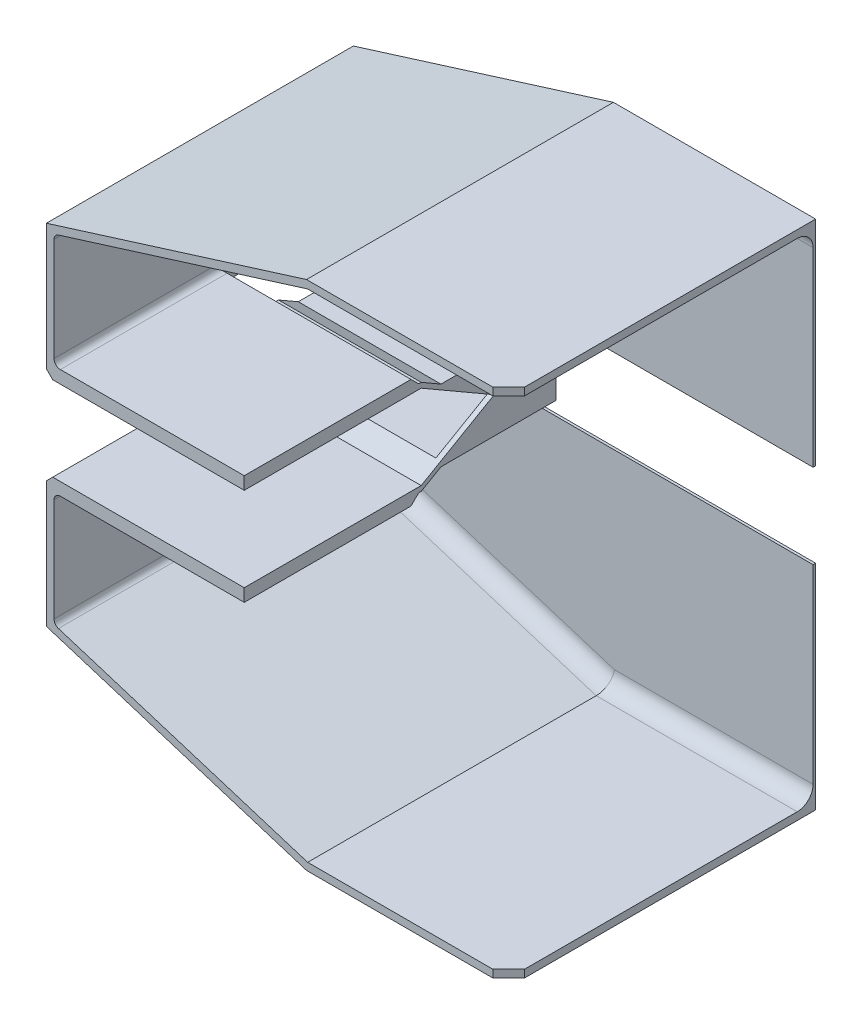
from build123d import *

# Parameters (mm, degrees)
BOSS_EXTRUDE1_DEPTH = 96
BOSS_EXTRUDE2_DEPTH = 2.4
SKETCH3_W           = 2.4
SKETCH3_H           = 61
CUT_EXTRUDE1_DEPTH  = 96
SKETCH4_W           = 143.4
SKETCH4_H           = 41
CUT_EXTRUDE2_DEPTH  = 5
SKETCH9_W           = 83.4
SKETCH9_H           = 55
CUT_EXTRUDE4_DEPTH  = 5
CUT_EXTRUDE3_DEPTH  = 60
BOSS_EXTRUDE3_DEPTH = 45
BOSS_EXTRUDE4_DEPTH = 1.6
CHAMFER1_SIZE       = 5
FILLET1_R           = 2
FILLET3_R           = 5
FILLET4_R           = 2
CHAMFER2_SIZE       = 1.6
CHAMFER3_SIZE       = 2


with BuildPart() as part:
    # Sketch1 → Boss-Extrude1 (new body)
    with BuildSketch(Plane.XY):
        Polygon((145.8, 0), (145.8, 65.8), (82.033733785, 65.8), (0, 40.164458192), (0, 0), (0, -1.6), (145.8, -1.6), align=None)
        Polygon((2.4, 38.4), (2.4, 2.4), (143.4, 2.4), (143.4, 63.4), (82.4, 63.4), align=None, mode=Mode.SUBTRACT)
    extrude(amount=BOSS_EXTRUDE1_DEPTH)

    # Sketch2 → Boss-Extrude2 (add)
    with BuildSketch(Plane(origin=(0, 0, 0), x_dir=(-1, 0, 0), z_dir=(0, 0, -1))):
        Polygon((-145.8, 0), (-145.8, 65.8), (-82.033733785, 65.8), (0, 40.164458192), (0, 0), (0, -1.6), (-145.8, -1.6), align=None)
    extrude(amount=BOSS_EXTRUDE2_DEPTH)

    # Sketch3 → Cut-Extrude1 (cut)
    with BuildSketch(Plane.XY.offset(96)):
        with Locations((144.6, 32.9)):
            Rectangle(SKETCH3_W, SKETCH3_H)
    extrude(amount=-CUT_EXTRUDE1_DEPTH, mode=Mode.SUBTRACT)

    # Sketch4 → Cut-Extrude2 (cut, through all)
    with BuildSketch(Plane(origin=(0, 2.4, 0), x_dir=(1, 0, 0), z_dir=(0, 1, 0))):
        with Locations((74.1, -20.5)):
            Rectangle(SKETCH4_W, SKETCH4_H)
    extrude(amount=-CUT_EXTRUDE2_DEPTH, mode=Mode.SUBTRACT)

    # Sketch9 → Cut-Extrude4 (cut, through all)
    with BuildSketch(Plane(origin=(0, 2.4, 0), x_dir=(1, 0, 0), z_dir=(0, 1, 0))):
        with Locations((104.1, -68.5)):
            Rectangle(SKETCH9_W, SKETCH9_H)
    extrude(amount=-CUT_EXTRUDE4_DEPTH, mode=Mode.SUBTRACT)

    # Sketch5 → Cut-Extrude3 (cut)
    with BuildSketch(Plane(origin=(62.4, 0, 0), x_dir=(0, 0, -1), z_dir=(1, 0, 0))):
        Polygon((-41, 0), (-43.4, 2.4), (-41, 2.4), align=None)
    extrude(amount=-CUT_EXTRUDE3_DEPTH, mode=Mode.SUBTRACT)

    # Sketch6 → Boss-Extrude3 (add)
    with BuildSketch(Plane(origin=(62.4, 0, 0), x_dir=(0, 0, -1), z_dir=(1, 0, 0))):
        Polygon((-40.2, 0), (-41, 0), (-41, -1.6), (-40.2, -1.6), (-33.964617093, -5.2), (2.4, -5.2), (2.4, -3.6), (-33.964617093, -3.6), align=None)
    extrude(amount=-BOSS_EXTRUDE3_DEPTH)

    # Sketch8 → Boss-Extrude4 (add)
    with BuildSketch(Plane(origin=(62.4, 0, 0), x_dir=(0, 0, -1), z_dir=(1, 0, 0))):
        Polygon((-33.964617093, -5.2), (2.4, -26.195121467), (2.4, -5.2), align=None)
    boss_extrude4 = extrude(amount=-BOSS_EXTRUDE4_DEPTH)

    # Mirror1: Boss-Extrude4 across plane
    add(boss_extrude4.mirror(Plane(origin=(39.9, 0, 0), x_dir=(0, 0, 1), z_dir=(1, 0, 0))))

    # Chamfer1
    chamfer1_edges = [part.edges().sort_by_distance(p)[0] for p in [
        (145.8, 64.6, 96),
    ]]
    chamfer(chamfer1_edges, length=CHAMFER1_SIZE)

    # Fillet1
    fillet1_edges = [part.edges().sort_by_distance(p)[0] for p in [
        (2.4, 2.4, 69.7),
    ]]
    fillet(fillet1_edges, radius=FILLET1_R)

    # Fillet3
    fillet3_edges = [part.edges().sort_by_distance(p)[0] for p in [
        (42.4, 50.9, 0),
        (2.4, 18.4, 0),
        (114.1, 63.4, 0),
    ]]
    fillet(fillet3_edges, radius=FILLET3_R)

    # Fillet4
    fillet4_edges = [part.edges().sort_by_distance(p)[0] for p in [
        (2.4, 38.4, 50.5),
    ]]
    fillet(fillet4_edges, radius=FILLET4_R)

    # Chamfer2
    chamfer2_edges = [part.edges().sort_by_distance(p)[0] for p in [
        (145.8, 32.1, -2.4),
        (72.9, -1.6, -2.4),
        (0, 19.282229096, -2.4),
        (41.016866893, 52.982229096, -2.4),
        (113.916866893, 65.8, -2.4),
    ]]
    chamfer(chamfer2_edges, length=CHAMFER2_SIZE)

    # Chamfer3
    chamfer3_edges = [part.edges().sort_by_distance(p)[0] for p in [
        (0, -1.6, 47.6),
    ]]
    chamfer(chamfer3_edges, length=CHAMFER3_SIZE)

    # Mirror2: part across plane


with BuildPart() as part_1:
    add(part.part)
    add(part.part.mirror(Plane.ZX.offset(-14.897560734)))


solid = part_1.part
